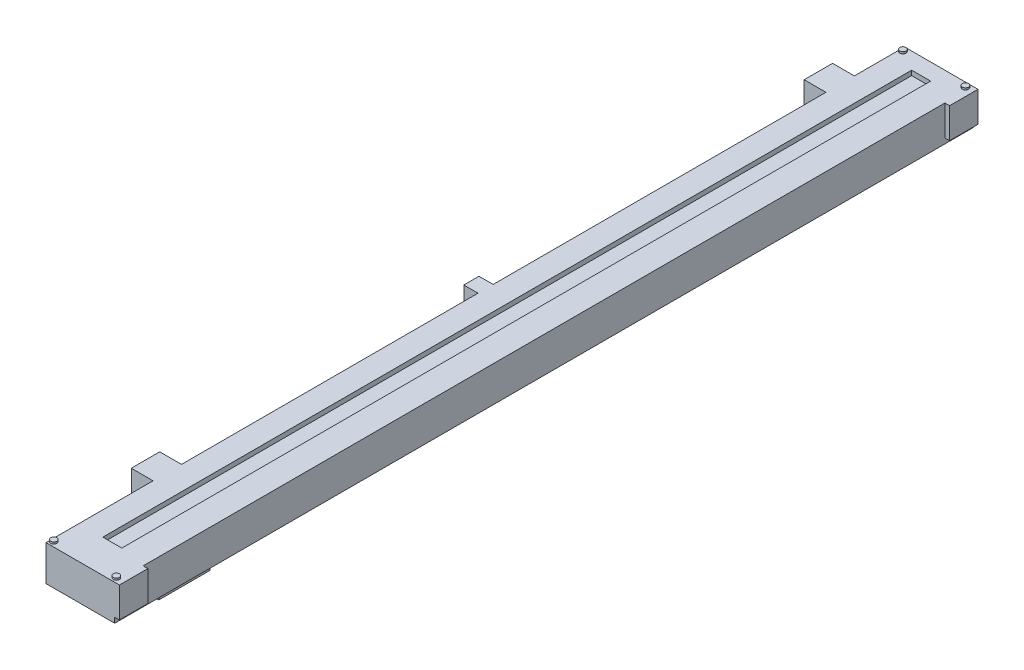
from build123d import *

# Parameters (mm, degrees)
SKETCH1_W           = 18.415
SKETCH1_H           = 230.1875
BOSS_EXTRUDE1_DEPTH = 9.525
SKETCH2_W           = 5.08
SKETCH2_H           = 216.8525
CUT_EXTRUDE1_DEPTH  = 1.27
SKETCH3_W           = 5.842
SKETCH3_H           = 7.62
SKETCH3_W_2         = 3.81
SKETCH3_H_2         = 4.064
SKETCH3_W_3         = 1.27
BOSS_EXTRUDE2_DEPTH = 8.128
SKETCH4_R           = 0.8255
BOSS_EXTRUDE3_DEPTH = 0.508
SKETCH5_W           = 5.08
SKETCH5_H           = 13.716
BOSS_EXTRUDE4_DEPTH = 2.794


with BuildPart() as part:
    # Sketch1 → Boss-Extrude1 (new body)
    with BuildSketch(Plane(origin=(0, 0, 0), x_dir=(1, 0, 0), z_dir=(0, 1, 0))):
        Rectangle(SKETCH1_W, SKETCH1_H)
    extrude(amount=BOSS_EXTRUDE1_DEPTH)

    # Sketch2 → Cut-Extrude1 (cut)
    with BuildSketch(Plane(origin=(0, 9.525, 0), x_dir=(1, 0, 0), z_dir=(0, 1, 0))):
        with Locations((-0.3175, 2.2225)):
            Rectangle(SKETCH2_W, SKETCH2_H)
    extrude(amount=-CUT_EXTRUDE1_DEPTH, mode=Mode.SUBTRACT)

    # Sketch3 → Boss-Extrude2 (add)
    with BuildSketch(Plane(origin=(0, 9.525, 0), x_dir=(1, 0, 0), z_dir=(0, 1, 0))):
        with Locations((-12.1285, 97.82175)):
            Rectangle(SKETCH3_W, SKETCH3_H)
        with Locations((-11.1125, 2.76225)):
            Rectangle(SKETCH3_W_2, SKETCH3_H_2)
        with Locations((-12.1285, -82.58175)):
            Rectangle(SKETCH3_W, SKETCH3_H)
        with Locations((9.8425, 111.28375)):
            Rectangle(SKETCH3_W_3, SKETCH3_H)
        with Locations((9.8425, -111.28375)):
            Rectangle(SKETCH3_W_3, SKETCH3_H)
    extrude(amount=-BOSS_EXTRUDE2_DEPTH)

    # Sketch4 → Boss-Extrude3 (add)
    with BuildSketch(Plane(origin=(0, 9.525, 0), x_dir=(1, 0, 0), z_dir=(0, 1, 0))):
        with Locations((-8.382, 113.82375)):
            Circle(SKETCH4_R)
        with Locations((8.382, 113.82375)):
            Circle(SKETCH4_R)
        with Locations((8.382, -113.82375)):
            Circle(SKETCH4_R)
        with Locations((-8.382, -113.82375)):
            Circle(SKETCH4_R)
    extrude(amount=BOSS_EXTRUDE3_DEPTH)

    # Sketch5 → Boss-Extrude4 (add)
    with BuildSketch(Plane.XZ):
        with Locations((4.3815, 94.11335)):
            Rectangle(SKETCH5_W, SKETCH5_H)
    extrude(amount=BOSS_EXTRUDE4_DEPTH)


solid = part.part
